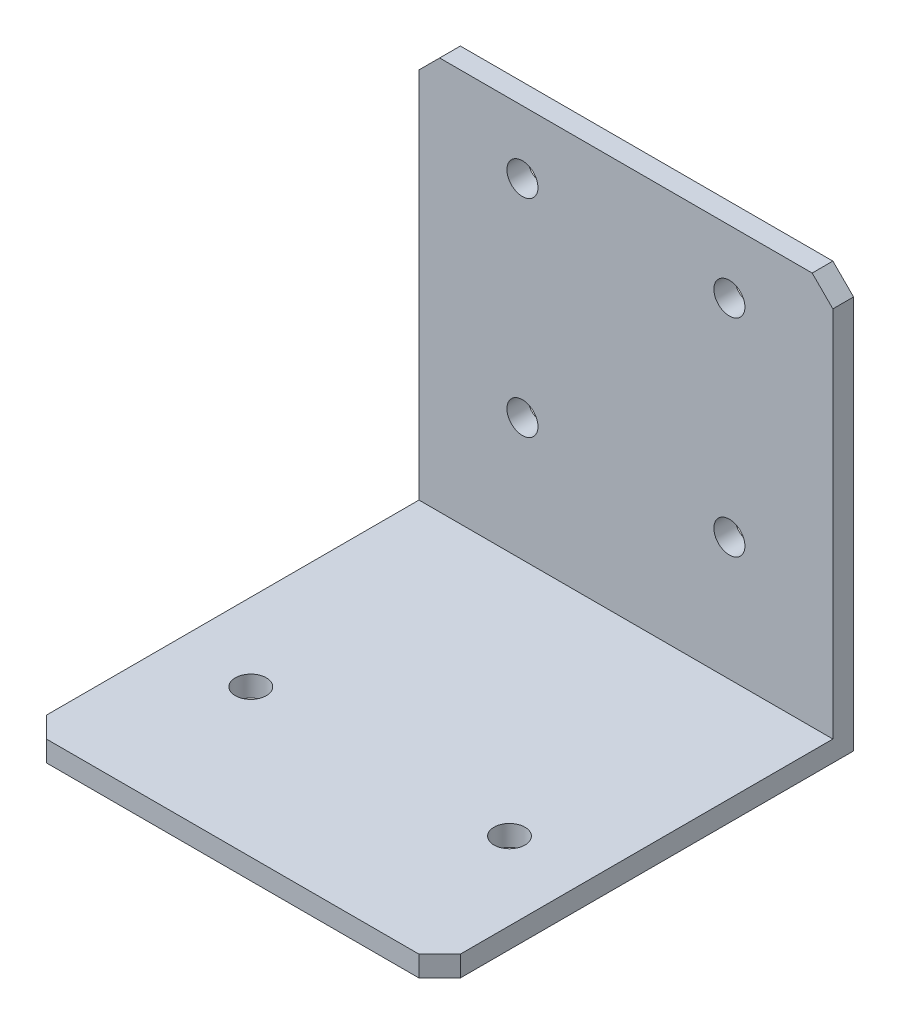
from build123d import *

# Parameters (mm, degrees)
EXTRUDE1_DEPTH = 40
EXTRUDE2_REACH = 42
SKETCH2_R      = 1.5
EXTRUDE3_REACH = 42
SKETCH3_R      = 1.5
CHAMFER1_SIZE  = 2


with BuildPart() as part:
    # Sketch1 → Extrude1 (new body)
    with BuildSketch(Plane(origin=(0, 0, 0), x_dir=(0, 0, -1), z_dir=(1, 0, 0))):
        Polygon((0, 0), (0, 38), (2, 38), (2, -2), (-38, -2), (-38, 0), align=None)
    extrude(amount=EXTRUDE1_DEPTH)

    # Sketch2 → Extrude2 (cut, up to next)
    with BuildSketch(Plane(origin=(0, -2, 0), x_dir=(-1, 0, 0), z_dir=(0, -1, 0)), mode=Mode.PRIVATE) as extrude2_sk1:
        with Locations((-32.5, -23.75)):
            Circle(SKETCH2_R)
    extrude2_tool1 = extrude(extrude2_sk1.sketch, amount=-EXTRUDE2_REACH, mode=Mode.PRIVATE) & part.part
    add(extrude2_tool1.solids().sort_by_distance((32.5, -2, 23.75))[0], mode=Mode.SUBTRACT)
    # Sketch2 → Extrude2 (cut, up to next)
    with BuildSketch(Plane(origin=(0, -2, 0), x_dir=(-1, 0, 0), z_dir=(0, -1, 0)), mode=Mode.PRIVATE) as extrude2_sk2:
        with Locations((-7.5, -23.75)):
            Circle(SKETCH2_R)
    extrude2_tool2 = extrude(extrude2_sk2.sketch, amount=-EXTRUDE2_REACH, mode=Mode.PRIVATE) & part.part
    add(extrude2_tool2.solids().sort_by_distance((7.5, -2, 23.75))[0], mode=Mode.SUBTRACT)

    # Sketch3 → Extrude3 (cut, up to next)
    with BuildSketch(Plane(origin=(0, 0, -2), x_dir=(-1, 0, 0), z_dir=(0, 0, -1)), mode=Mode.PRIVATE) as extrude3_sk1:
        with Locations((-10, 31.9)):
            Circle(SKETCH3_R)
    extrude3_tool1 = extrude(extrude3_sk1.sketch, amount=-EXTRUDE3_REACH, mode=Mode.PRIVATE) & part.part
    add(extrude3_tool1.solids().sort_by_distance((10, 31.9, -2))[0], mode=Mode.SUBTRACT)
    # Sketch3 → Extrude3 (cut, up to next)
    with BuildSketch(Plane(origin=(0, 0, -2), x_dir=(-1, 0, 0), z_dir=(0, 0, -1)), mode=Mode.PRIVATE) as extrude3_sk2:
        with Locations((-30, 31.9)):
            Circle(SKETCH3_R)
    extrude3_tool2 = extrude(extrude3_sk2.sketch, amount=-EXTRUDE3_REACH, mode=Mode.PRIVATE) & part.part
    add(extrude3_tool2.solids().sort_by_distance((30, 31.9, -2))[0], mode=Mode.SUBTRACT)
    # Sketch3 → Extrude3 (cut, up to next)
    with BuildSketch(Plane(origin=(0, 0, -2), x_dir=(-1, 0, 0), z_dir=(0, 0, -1)), mode=Mode.PRIVATE) as extrude3_sk3:
        with Locations((-30, 11.9)):
            Circle(SKETCH3_R)
    extrude3_tool3 = extrude(extrude3_sk3.sketch, amount=-EXTRUDE3_REACH, mode=Mode.PRIVATE) & part.part
    add(extrude3_tool3.solids().sort_by_distance((30, 11.9, -2))[0], mode=Mode.SUBTRACT)
    # Sketch3 → Extrude3 (cut, up to next)
    with BuildSketch(Plane(origin=(0, 0, -2), x_dir=(-1, 0, 0), z_dir=(0, 0, -1)), mode=Mode.PRIVATE) as extrude3_sk4:
        with Locations((-10, 11.9)):
            Circle(SKETCH3_R)
    extrude3_tool4 = extrude(extrude3_sk4.sketch, amount=-EXTRUDE3_REACH, mode=Mode.PRIVATE) & part.part
    add(extrude3_tool4.solids().sort_by_distance((10, 11.9, -2))[0], mode=Mode.SUBTRACT)

    # Chamfer1
    chamfer1_edges = [part.edges().sort_by_distance(p)[0] for p in [
        (40, 38, -1),
        (0, 38, -1),
        (40, -1, 38),
        (0, -1, 38),
    ]]
    chamfer(chamfer1_edges, length=CHAMFER1_SIZE)


solid = part.part
